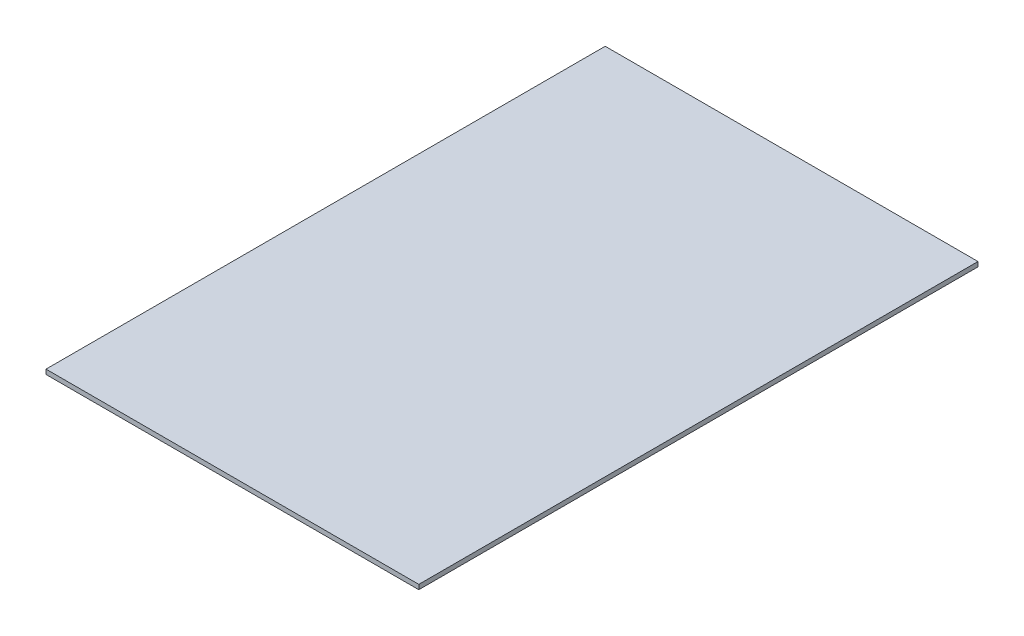
from build123d import *

# Parameters (mm, degrees)
SKIZZE2_W                       = 800
SKIZZE2_H                       = 1200
AUFSATZ_LINEAR_AUSTRAGEN1_DEPTH = 10


with BuildPart() as part:
    # Skizze2 → Aufsatz-Linear austragen1 (new body)
    with BuildSketch(Plane(origin=(0, 0, 0), x_dir=(1, 0, 0), z_dir=(0, 1, 0))):
        Rectangle(SKIZZE2_W, SKIZZE2_H)
    extrude(amount=AUFSATZ_LINEAR_AUSTRAGEN1_DEPTH)


solid = part.part
